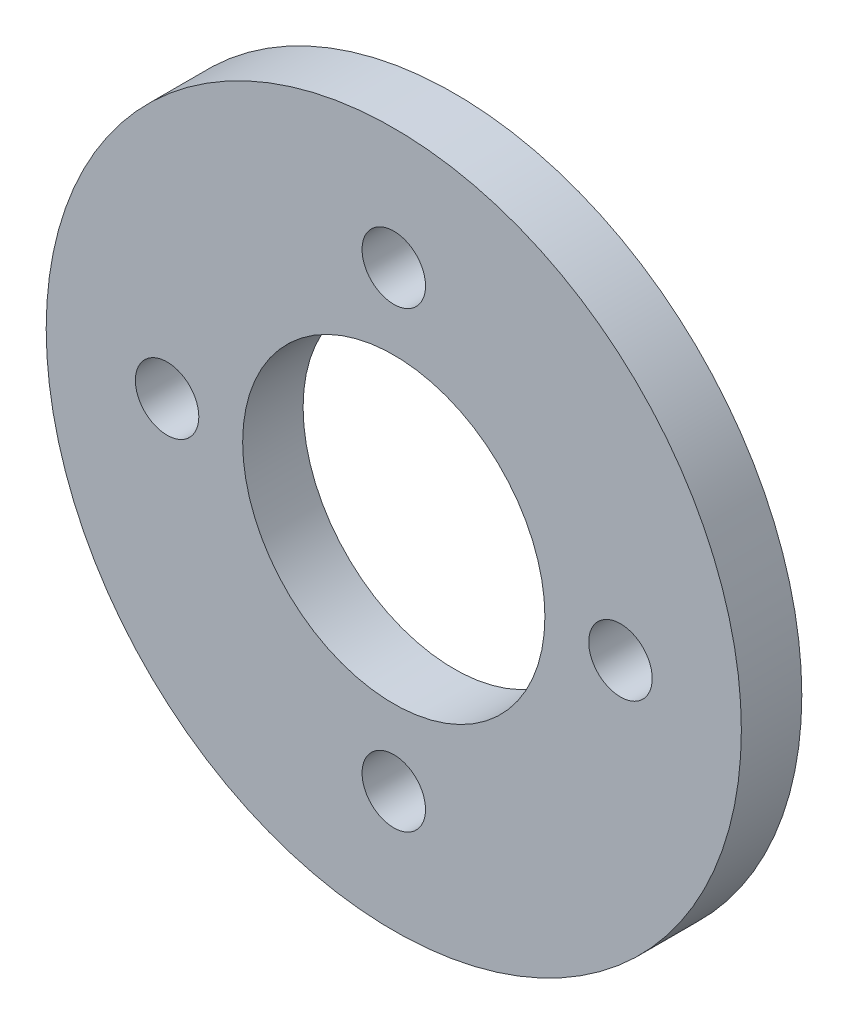
from build123d import *

# Parameters (mm, degrees)
SKETCH1_R           = 23
SKETCH1_R_2         = 2.1
SKETCH1_R_3         = 10
BOSS_EXTRUDE1_DEPTH = 4


with BuildPart() as part:
    # Sketch1 → Boss-Extrude1 (new body)
    with BuildSketch(Plane.XY):
        Circle(SKETCH1_R)
        with Locations((0, 15)):
            Circle(SKETCH1_R_2, mode=Mode.SUBTRACT)
        with Locations((15, 0)):
            Circle(SKETCH1_R_2, mode=Mode.SUBTRACT)
        with Locations((0, -15)):
            Circle(SKETCH1_R_2, mode=Mode.SUBTRACT)
        with Locations((-15, 0)):
            Circle(SKETCH1_R_2, mode=Mode.SUBTRACT)
        Circle(SKETCH1_R_3, mode=Mode.SUBTRACT)
    extrude(amount=BOSS_EXTRUDE1_DEPTH)


solid = part.part
